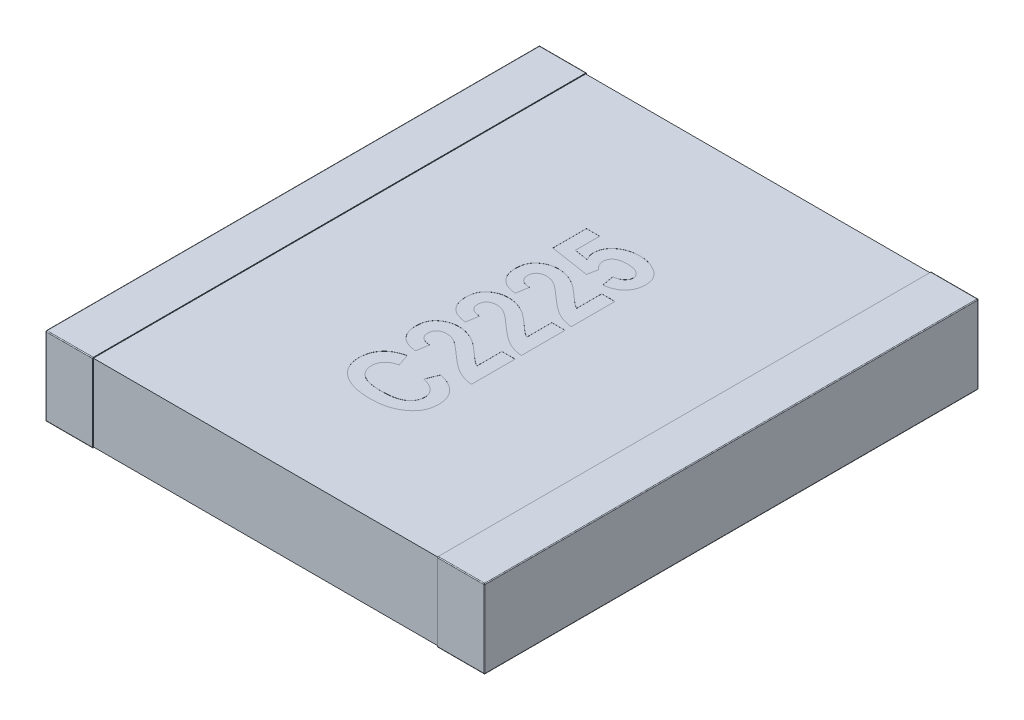
from build123d import *

# Parameters (mm, degrees)
SKETCH1_W            = 0.6
SKETCH1_H            = 6.3
THICKNESS_DEPTH      = 1
FILLET1_R            = 0.01
SKETCH2_W            = 6.28
SKETCH2_H            = 0.98
BOSS_EXTRUDE2_DEPTH  = 2.2
FILLET1_OF_MIRROR3_R = 0.01
CUT_EXTRUDE1_DEPTH   = 0.001


with BuildPart() as part:
    # Sketch1 → THICKNESS (new body)
    with BuildSketch(Plane(origin=(0, 0, 0), x_dir=(1, 0, 0), z_dir=(0, 1, 0))):
        with Locations((-2.5, 0)):
            Rectangle(SKETCH1_W, SKETCH1_H)
    thickness = extrude(amount=THICKNESS_DEPTH)

    # Fillet1
    fillet1_edges = [part.edges().sort_by_distance(p)[0] for p in [
        (-2.5, 1, -3.15),
        (-2.8, 1, 0),
        (-2.5, 0, -3.15),
        (-2.5, 0, 3.15),
        (-2.8, 0, 0),
        (-2.5, 1, 3.15),
        (-2.8, 0.5, -3.15),
        (-2.8, 0.5, 3.15),
    ]]
    fillet(fillet1_edges, radius=FILLET1_R)

    # Sketch2 → Boss-Extrude2 (add)
    with BuildSketch(Plane(origin=(0, 0, 0), x_dir=(0, 0, -1), z_dir=(1, 0, 0))):
        with Locations((0, 0.5)):
            Rectangle(SKETCH2_W, SKETCH2_H)
    boss_extrude2 = extrude(amount=-BOSS_EXTRUDE2_DEPTH)

    # Mirror3: THICKNESS, Boss-Extrude2 across plane
    add(thickness.mirror(Plane(origin=(0, 0, 0), x_dir=(0, 0, 1), z_dir=(1, 0, 0))))
    add(boss_extrude2.mirror(Plane(origin=(0, 0, 0), x_dir=(0, 0, 1), z_dir=(1, 0, 0))))

    # Fillet1 of Mirror3
    fillet1_of_mirror3_edges = [part.edges().sort_by_distance(p)[0] for p in [
        (2.5, 1, -3.15),
        (2.8, 1, 0),
        (2.5, 0, -3.15),
        (2.5, 0, 3.15),
        (2.8, 0, 0),
        (2.5, 1, 3.15),
        (2.8, 0.5, -3.15),
        (2.8, 0.5, 3.15),
    ]]
    fillet(fillet1_of_mirror3_edges, radius=FILLET1_OF_MIRROR3_R)

    # Sketch3 → Cut-Extrude1 (cut)
    with BuildSketch(Plane(origin=(0, 0.99, 0), x_dir=(1, 0, 0), z_dir=(0, 1, 0))):
        with BuildLine():
            Line((0.136363636, -1.26461039), (0.201298701, -1.108766234))
            add(Edge.make_bspline(
                [(0.201298701, -1.108766234), (0.214398679, -1.111985135), (0.239924634, -1.118257322), (0.276411029, -1.130118641), (0.310255179, -1.143188018), (0.341258619, -1.158054192), (0.369599325, -1.174483479), (0.395222463, -1.192525745), (0.418170449, -1.212112299), (0.438365598, -1.233268297), (0.455765912, -1.255956545), (0.471194946, -1.279625275), (0.484182898, -1.304628847), (0.4948407, -1.330978242), (0.502829618, -1.358620135), (0.508820757, -1.387435299), (0.512253899, -1.417530362), (0.512739893, -1.438032668), (0.512987013, -1.448457792)],
                knots=[0, 0, 0, 0, 4.0457e-05, 7.8832e-05, 0.000115008, 0.000149225, 0.00018187, 0.000213174, 0.000243107, 0.000272244, 0.000300738, 0.000328768, 0.000356904, 0.000385128, 0.000413894, 0.000443105, 0.000473335, 0.000504609, 0.000504609, 0.000504609, 0.000504609], degree=3))
            add(Edge.make_bspline(
                [(0.512987013, -1.448457792), (0.512692936, -1.461538079), (0.512116846, -1.487162052), (0.505918262, -1.524552352), (0.496500592, -1.560132443), (0.48297676, -1.593838191), (0.465690424, -1.625709563), (0.444278756, -1.655409865), (0.419538879, -1.683632129), (0.400249065, -1.700041432), (0.390422078, -1.708400974)],
                knots=[0, 0, 0, 0, 3.9207e-05, 7.6805e-05, 0.000113379, 0.00014944, 0.00018549, 0.000221864, 0.00025909, 0.000297748, 0.000297748, 0.000297748, 0.000297748], degree=3))
            add(Edge.make_bspline(
                [(0.390422078, -1.708400974), (0.378289428, -1.717589791), (0.353847085, -1.736101511), (0.313541703, -1.759341949), (0.270240344, -1.779108387), (0.223903762, -1.795286241), (0.17448062, -1.807896026), (0.121947356, -1.816711903), (0.066329381, -1.822006106), (0.028218004, -1.822698049), (0.008725649, -1.823051948)],
                knots=[0, 0, 0, 0, 4.5623e-05, 9.1911e-05, 0.00013922, 0.000188252, 0.000238945, 0.000292054, 0.000347905, 0.000406375, 0.000406375, 0.000406375, 0.000406375], degree=3))
            add(Edge.make_bspline(
                [(0.008725649, -1.823051948), (-0.011851286, -1.822728635), (-0.051931704, -1.822098877), (-0.110284982, -1.816428854), (-0.165298235, -1.807785146), (-0.216766987, -1.794897738), (-0.264986777, -1.77875342), (-0.309656912, -1.758807161), (-0.351244574, -1.735647553), (-0.376082128, -1.71675196), (-0.388392857, -1.707386364)],
                knots=[0, 0, 0, 0, 6.1715e-05, 0.000120211, 0.000175723, 0.00022863, 0.000279196, 0.000328068, 0.000375235, 0.000421589, 0.000421589, 0.000421589, 0.000421589], degree=3))
            add(Edge.make_bspline(
                [(-0.388392857, -1.707386364), (-0.398345965, -1.698883783), (-0.417961407, -1.68212702), (-0.443331204, -1.653469471), (-0.46499687, -1.622771098), (-0.482313096, -1.589708631), (-0.496435559, -1.554719195), (-0.506038208, -1.517403394), (-0.511790154, -1.477925698), (-0.512581962, -1.450912702), (-0.512987013, -1.437094156)],
                knots=[0, 0, 0, 0, 3.9231e-05, 7.7316e-05, 0.000114471, 0.000151689, 0.000189032, 0.000227423, 0.000266997, 0.000308443, 0.000308443, 0.000308443, 0.000308443], degree=3))
            add(Edge.make_bspline(
                [(-0.512987013, -1.437094156), (-0.512716343, -1.425786249), (-0.512184355, -1.40356109), (-0.507931398, -1.370971923), (-0.500453169, -1.339922729), (-0.490644065, -1.310110424), (-0.477519585, -1.281796563), (-0.461593795, -1.254899278), (-0.442919053, -1.229312793), (-0.428401184, -1.213804419), (-0.421063312, -1.205965909)],
                knots=[0, 0, 0, 0, 3.3918e-05, 6.6664e-05, 9.8361e-05, 0.000129612, 0.000160664, 0.000191777, 0.000223272, 0.000255459, 0.000255459, 0.000255459, 0.000255459], degree=3))
            add(Edge.make_bspline(
                [(-0.421063312, -1.205965909), (-0.415407881, -1.200515869), (-0.403883704, -1.18941022), (-0.384471947, -1.174456438), (-0.363093659, -1.160611831), (-0.339657607, -1.148124617), (-0.314392853, -1.136515651), (-0.28716989, -1.12595942), (-0.257926787, -1.116672878), (-0.237648602, -1.111442498), (-0.227272727, -1.108766234)],
                knots=[0, 0, 0, 0, 2.3548e-05, 4.7984e-05, 7.3368e-05, 9.988e-05, 0.000127573, 0.00015674, 0.000187416, 0.000219558, 0.000219558, 0.000219558, 0.000219558], degree=3))
            Line((-0.227272727, -1.108766234), (-0.175324675, -1.26461039))
            add(Edge.make_bspline(
                [(-0.175324675, -1.26461039), (-0.181975902, -1.266074849), (-0.194918084, -1.268924443), (-0.213595413, -1.274645704), (-0.230942941, -1.28161111), (-0.247377118, -1.289189563), (-0.262329513, -1.298315282), (-0.276514559, -1.307861071), (-0.28908196, -1.319054403), (-0.300692084, -1.330879848), (-0.310725155, -1.343754524), (-0.319798502, -1.356932912), (-0.327342325, -1.37080791), (-0.333409456, -1.385321642), (-0.338319598, -1.400302206), (-0.341772531, -1.415861229), (-0.34386351, -1.431963105), (-0.34405743, -1.442904873), (-0.344155844, -1.448457792)],
                knots=[0, 0, 0, 0, 2.0427e-05, 3.9747e-05, 5.8513e-05, 7.6485e-05, 9.3955e-05, 0.000111011, 0.000127695, 0.000144342, 0.000160663, 0.000176591, 0.0001923, 0.000207941, 0.000223727, 0.00023953, 0.000255689, 0.00027234, 0.00027234, 0.00027234, 0.00027234], degree=3))
            add(Edge.make_bspline(
                [(-0.344155844, -1.448457792), (-0.343922857, -1.456316567), (-0.343464314, -1.47178344), (-0.339815571, -1.494443473), (-0.333363218, -1.515883972), (-0.324888303, -1.536422831), (-0.313613243, -1.555733213), (-0.299927204, -1.573922482), (-0.283681663, -1.590818388), (-0.265141061, -1.606782958), (-0.243666159, -1.621411475), (-0.218738348, -1.633644713), (-0.190654932, -1.643900096), (-0.159545627, -1.652662188), (-0.125189618, -1.659232534), (-0.087627914, -1.663787955), (-0.046918653, -1.666632217), (-0.018673729, -1.667011522), (-0.004058442, -1.667207792)],
                knots=[0, 0, 0, 0, 2.357e-05, 4.6389e-05, 6.8605e-05, 9.0614e-05, 0.00011289, 0.000135495, 0.000158747, 0.000183068, 0.000208789, 0.000236468, 0.000266132, 0.000298382, 0.000333323, 0.000370951, 0.000411838, 0.00045568, 0.00045568, 0.00045568, 0.00045568], degree=3))
            add(Edge.make_bspline(
                [(-0.004058442, -1.667207792), (0.011095871, -1.666985985), (0.040278488, -1.666558851), (0.08242797, -1.664069004), (0.121153689, -1.659336396), (0.156607918, -1.653278299), (0.188583424, -1.64498836), (0.217099791, -1.634860599), (0.242435415, -1.623195029), (0.264257887, -1.609279255), (0.283097178, -1.593860302), (0.299453787, -1.577467135), (0.313117458, -1.559783266), (0.32469734, -1.541281785), (0.333472268, -1.52145475), (0.339442532, -1.500536726), (0.343571874, -1.478651768), (0.343958581, -1.463629112), (0.344155844, -1.455965909)],
                knots=[0, 0, 0, 0, 4.5466e-05, 8.7553e-05, 0.000126592, 0.000162456, 0.000195383, 0.00022555, 0.000253145, 0.000278871, 0.000302958, 0.000326059, 0.000348182, 0.000369864, 0.000391395, 0.00041297, 0.000435022, 0.000457984, 0.000457984, 0.000457984, 0.000457984], degree=3))
            add(Edge.make_bspline(
                [(0.344155844, -1.455965909), (0.343974101, -1.450347695), (0.343613575, -1.439202733), (0.341524436, -1.422749638), (0.337179679, -1.407037059), (0.33212763, -1.391651473), (0.324835159, -1.377083413), (0.316327699, -1.362949716), (0.306090095, -1.349513466), (0.294241166, -1.336708849), (0.280890082, -1.324504127), (0.265656465, -1.313231761), (0.248554845, -1.302946712), (0.229614222, -1.293426308), (0.208948136, -1.284715932), (0.186414075, -1.277031267), (0.162119865, -1.270078743), (0.145114413, -1.266468283), (0.136363636, -1.26461039)],
                knots=[0, 0, 0, 0, 1.6862e-05, 3.345e-05, 4.9593e-05, 6.5701e-05, 8.1946e-05, 9.8338e-05, 0.00011514, 0.000132516, 0.000150616, 0.000169326, 0.000189267, 0.000210412, 0.000232874, 0.00025649, 0.000281799, 0.000308629, 0.000308629, 0.000308629, 0.000308629], degree=3))
        make_face()
        with BuildLine():
            Line((0.331168831, -0.459415584), (0.5, -0.459415584))
            Line((0.5, -0.459415584), (0.5, -1.017857143))
            add(Edge.make_bspline(
                [(0.5, -1.017857143), (0.483371878, -1.015892291), (0.450160812, -1.011967927), (0.401416985, -1.000084764), (0.353798597, -0.984066439), (0.315024186, -0.966526313), (0.283716795, -0.949119933), (0.258172511, -0.933548747), (0.230990775, -0.915005151), (0.202208417, -0.893511307), (0.171398924, -0.869678521), (0.138885435, -0.842979694), (0.104639318, -0.813553873), (0.081403726, -0.792789394), (0.069399351, -0.782061688)],
                knots=[0, 0, 0, 0, 5.0192e-05, 0.000100248, 0.000150173, 0.000200756, 0.00022764, 0.000257605, 0.000290474, 0.000326311, 0.000365358, 0.00040732, 0.000452506, 0.000500804, 0.000500804, 0.000500804, 0.000500804], degree=3))
            add(Edge.make_bspline(
                [(0.069399351, -0.782061688), (0.060018232, -0.773650469), (0.042071313, -0.757559057), (0.016082491, -0.734925087), (-0.00728779, -0.714565899), (-0.028521986, -0.697130314), (-0.047176105, -0.682003958), (-0.06353451, -0.669467923), (-0.077455394, -0.659371865), (-0.086213896, -0.653975522), (-0.090097403, -0.651582792)],
                knots=[0, 0, 0, 0, 3.7799e-05, 7.2312e-05, 0.00010339, 0.000130775, 0.000154734, 0.000175433, 0.000192606, 0.000206286, 0.000206286, 0.000206286, 0.000206286], degree=3))
            add(Edge.make_bspline(
                [(-0.090097403, -0.651582792), (-0.100045175, -0.646029626), (-0.119463446, -0.635189724), (-0.150235139, -0.623901678), (-0.181062308, -0.61652335), (-0.201799466, -0.615677832), (-0.212053571, -0.61525974)],
                knots=[0, 0, 0, 0, 3.4128e-05, 6.6618e-05, 9.8026e-05, 0.000128749, 0.000128749, 0.000128749, 0.000128749], degree=3))
            add(Edge.make_bspline(
                [(-0.212053571, -0.61525974), (-0.22230063, -0.615615259), (-0.241698968, -0.616288277), (-0.268837794, -0.622164857), (-0.292263142, -0.631782125), (-0.311201971, -0.645916208), (-0.326112443, -0.662958398), (-0.336660208, -0.682820666), (-0.343144596, -0.70509122), (-0.343811987, -0.720801666), (-0.344155844, -0.728896104)],
                knots=[0, 0, 0, 0, 3.0708e-05, 5.8133e-05, 8.2859e-05, 0.000106074, 0.000128371, 0.000150251, 0.000173051, 0.000197284, 0.000197284, 0.000197284, 0.000197284], degree=3))
            add(Edge.make_bspline(
                [(-0.344155844, -0.728896104), (-0.343772419, -0.737670497), (-0.343037518, -0.754488158), (-0.336195521, -0.778141548), (-0.324916913, -0.798671474), (-0.308547663, -0.815495127), (-0.288097037, -0.829302728), (-0.262958615, -0.839271534), (-0.233609955, -0.84610636), (-0.212498526, -0.848013969), (-0.201298701, -0.849025974)],
                knots=[0, 0, 0, 0, 2.6272e-05, 5.0355e-05, 7.3159e-05, 9.5837e-05, 0.000120095, 0.000146662, 0.000176489, 0.000210192, 0.000210192, 0.000210192, 0.000210192], degree=3))
            Line((-0.201298701, -0.849025974), (-0.227272727, -1.00487013))
            add(Edge.make_bspline(
                [(-0.227272727, -1.00487013), (-0.238664931, -1.003565149), (-0.260764459, -1.00103364), (-0.292507359, -0.994330333), (-0.322012621, -0.986391685), (-0.349127549, -0.976451527), (-0.37388751, -0.964663722), (-0.396265212, -0.950988332), (-0.416637199, -0.935819653), (-0.43431516, -0.91839216), (-0.449781056, -0.899401271), (-0.463317835, -0.878975162), (-0.474637136, -0.856963449), (-0.484076171, -0.833558125), (-0.491064393, -0.808547357), (-0.496414197, -0.782185581), (-0.499431636, -0.754264017), (-0.499807758, -0.735193632), (-0.5, -0.725446429)],
                knots=[0, 0, 0, 0, 3.4382e-05, 6.6697e-05, 9.722e-05, 0.000125982, 0.00015321, 0.000179346, 0.00020455, 0.000229231, 0.000253603, 0.000277916, 0.000302603, 0.000327737, 0.000353492, 0.000380394, 0.00040836, 0.000437599, 0.000437599, 0.000437599, 0.000437599], degree=3))
            add(Edge.make_bspline(
                [(-0.5, -0.725446429), (-0.499707252, -0.714748711), (-0.49914014, -0.694025097), (-0.495333259, -0.663876643), (-0.488609048, -0.635888959), (-0.479514345, -0.609728461), (-0.467494659, -0.585778667), (-0.452919977, -0.56371043), (-0.435652695, -0.543793565), (-0.415760674, -0.526218603), (-0.39445374, -0.510527101), (-0.372035902, -0.496966792), (-0.349004815, -0.485171736), (-0.325006155, -0.475963616), (-0.30032419, -0.468554826), (-0.274925758, -0.463358785), (-0.248741747, -0.459912386), (-0.231004194, -0.459582902), (-0.221996753, -0.459415584)],
                knots=[0, 0, 0, 0, 3.2093e-05, 6.2171e-05, 9.0964e-05, 0.000118305, 0.000145076, 0.000171134, 0.000197458, 0.000223899, 0.000250604, 0.00027674, 0.000302423, 0.000328123, 0.00035374, 0.000379648, 0.000405824, 0.000432832, 0.000432832, 0.000432832, 0.000432832], degree=3))
            add(Edge.make_bspline(
                [(-0.221996753, -0.459415584), (-0.211773706, -0.459590374), (-0.191410581, -0.459938534), (-0.161178194, -0.463361848), (-0.131385861, -0.468565635), (-0.10202543, -0.476149683), (-0.072835323, -0.486003816), (-0.043622997, -0.497996531), (-0.014293782, -0.51220863), (0.010007277, -0.526203142), (0.030196203, -0.538742578), (0.04633337, -0.549908545), (0.063414235, -0.562633839), (0.081726202, -0.576561682), (0.100916784, -0.59223819), (0.121214355, -0.609281076), (0.142523538, -0.627749929), (0.156945101, -0.640671559), (0.164366883, -0.647321429)],
                knots=[0, 0, 0, 0, 3.0658e-05, 6.1067e-05, 9.116e-05, 0.00012133, 0.000151939, 0.000183517, 0.000216008, 0.000249634, 0.000267595, 0.000287295, 0.00030848, 0.000331493, 0.000356308, 0.000382809, 0.000411004, 0.000440899, 0.000440899, 0.000440899, 0.000440899], degree=3))
            add(Edge.make_bspline(
                [(0.164366883, -0.647321429), (0.171180839, -0.653496647), (0.184209265, -0.665303794), (0.203055408, -0.681820497), (0.219965729, -0.696701309), (0.234932252, -0.709879979), (0.248114972, -0.721334967), (0.259635965, -0.730767563), (0.269243968, -0.738543099), (0.283565888, -0.749965898), (0.30373791, -0.763614786), (0.322291451, -0.773484007), (0.331168831, -0.778206169)],
                knots=[0, 0, 0, 0, 2.7587e-05, 5.2747e-05, 7.5177e-05, 9.5163e-05, 0.000112573, 0.000127565, 0.000139829, 0.000149654, 0.000182523, 0.000212679, 0.000212679, 0.000212679, 0.000212679], degree=3))
            Line((0.331168831, -0.778206169), (0.331168831, -0.459415584))
        make_face()
        with BuildLine():
            Line((0.331168831, 0.176948052), (0.5, 0.176948052))
            Line((0.5, 0.176948052), (0.5, -0.381493506))
            add(Edge.make_bspline(
                [(0.5, -0.381493506), (0.483371878, -0.379528655), (0.450160812, -0.37560429), (0.401416985, -0.363721127), (0.353798597, -0.347702803), (0.315024186, -0.330162677), (0.283716795, -0.312756297), (0.258172511, -0.29718511), (0.230990775, -0.278641515), (0.202208417, -0.25714767), (0.171398924, -0.233314885), (0.138885435, -0.206616058), (0.104639318, -0.177190236), (0.081403726, -0.156425758), (0.069399351, -0.145698052)],
                knots=[0, 0, 0, 0, 5.0192e-05, 0.000100248, 0.000150173, 0.000200756, 0.00022764, 0.000257605, 0.000290474, 0.000326311, 0.000365358, 0.00040732, 0.000452506, 0.000500804, 0.000500804, 0.000500804, 0.000500804], degree=3))
            add(Edge.make_bspline(
                [(0.069399351, -0.145698052), (0.060018232, -0.137286833), (0.042071313, -0.12119542), (0.016082491, -0.098561451), (-0.00728779, -0.078202263), (-0.028521986, -0.060766677), (-0.047176105, -0.045640321), (-0.06353451, -0.033104287), (-0.077455394, -0.023008229), (-0.086213896, -0.017611886), (-0.090097403, -0.015219156)],
                knots=[0, 0, 0, 0, 3.7799e-05, 7.2312e-05, 0.00010339, 0.000130775, 0.000154734, 0.000175433, 0.000192606, 0.000206286, 0.000206286, 0.000206286, 0.000206286], degree=3))
            add(Edge.make_bspline(
                [(-0.090097403, -0.015219156), (-0.100045175, -0.00966599), (-0.119463446, 0.001173913), (-0.150235139, 0.012461958), (-0.181062308, 0.019840286), (-0.201799466, 0.020685804), (-0.212053571, 0.021103896)],
                knots=[0, 0, 0, 0, 3.4128e-05, 6.6618e-05, 9.8026e-05, 0.000128749, 0.000128749, 0.000128749, 0.000128749], degree=3))
            add(Edge.make_bspline(
                [(-0.212053571, 0.021103896), (-0.22230063, 0.020748378), (-0.241698968, 0.020075359), (-0.268837794, 0.01419878), (-0.292263142, 0.004581511), (-0.311201971, -0.009552572), (-0.326112443, -0.026594762), (-0.336660208, -0.04645703), (-0.343144596, -0.068727584), (-0.343811987, -0.08443803), (-0.344155844, -0.092532468)],
                knots=[0, 0, 0, 0, 3.0708e-05, 5.8133e-05, 8.2859e-05, 0.000106074, 0.000128371, 0.000150251, 0.000173051, 0.000197284, 0.000197284, 0.000197284, 0.000197284], degree=3))
            add(Edge.make_bspline(
                [(-0.344155844, -0.092532468), (-0.343772419, -0.10130686), (-0.343037518, -0.118124521), (-0.336195521, -0.141777911), (-0.324916913, -0.162307837), (-0.308547663, -0.179131491), (-0.288097037, -0.192939091), (-0.262958615, -0.202907897), (-0.233609955, -0.209742724), (-0.212498526, -0.211650332), (-0.201298701, -0.212662338)],
                knots=[0, 0, 0, 0, 2.6272e-05, 5.0355e-05, 7.3159e-05, 9.5837e-05, 0.000120095, 0.000146662, 0.000176489, 0.000210192, 0.000210192, 0.000210192, 0.000210192], degree=3))
            Line((-0.201298701, -0.212662338), (-0.227272727, -0.368506494))
            add(Edge.make_bspline(
                [(-0.227272727, -0.368506494), (-0.238664931, -0.367201512), (-0.260764459, -0.364670003), (-0.292507359, -0.357966697), (-0.322012621, -0.350028049), (-0.349127549, -0.34008789), (-0.37388751, -0.328300085), (-0.396265212, -0.314624695), (-0.416637199, -0.299456017), (-0.43431516, -0.282028523), (-0.449781056, -0.263037635), (-0.463317835, -0.242611526), (-0.474637136, -0.220599813), (-0.484076171, -0.197194489), (-0.491064393, -0.17218372), (-0.496414197, -0.145821945), (-0.499431636, -0.11790038), (-0.499807758, -0.098829996), (-0.5, -0.089082792)],
                knots=[0, 0, 0, 0, 3.4382e-05, 6.6697e-05, 9.722e-05, 0.000125982, 0.00015321, 0.000179346, 0.00020455, 0.000229231, 0.000253603, 0.000277916, 0.000302603, 0.000327737, 0.000353492, 0.000380394, 0.00040836, 0.000437599, 0.000437599, 0.000437599, 0.000437599], degree=3))
            add(Edge.make_bspline(
                [(-0.5, -0.089082792), (-0.499707252, -0.078385075), (-0.49914014, -0.05766146), (-0.495333259, -0.027513007), (-0.488609048, 0.000474678), (-0.479514345, 0.026635175), (-0.467494659, 0.050584969), (-0.452919977, 0.072653206), (-0.435652695, 0.092570071), (-0.415760674, 0.110145033), (-0.39445374, 0.125836536), (-0.372035902, 0.139396844), (-0.349004815, 0.151191901), (-0.325006155, 0.160400021), (-0.30032419, 0.16780881), (-0.274925758, 0.173004852), (-0.248741747, 0.176451251), (-0.231004194, 0.176780734), (-0.221996753, 0.176948052)],
                knots=[0, 0, 0, 0, 3.2093e-05, 6.2171e-05, 9.0964e-05, 0.000118305, 0.000145076, 0.000171134, 0.000197458, 0.000223899, 0.000250604, 0.00027674, 0.000302423, 0.000328123, 0.00035374, 0.000379648, 0.000405824, 0.000432832, 0.000432832, 0.000432832, 0.000432832], degree=3))
            add(Edge.make_bspline(
                [(-0.221996753, 0.176948052), (-0.211773706, 0.176773263), (-0.191410581, 0.176425102), (-0.161178194, 0.173001789), (-0.131385861, 0.167798002), (-0.10202543, 0.160213954), (-0.072835323, 0.150359821), (-0.043622997, 0.138367105), (-0.014293782, 0.124155006), (0.010007277, 0.110160495), (0.030196203, 0.097621059), (0.04633337, 0.086455091), (0.063414235, 0.073729797), (0.081726202, 0.059801955), (0.100916784, 0.044125446), (0.121214355, 0.027082561), (0.142523538, 0.008613708), (0.156945101, -0.004307922), (0.164366883, -0.010957792)],
                knots=[0, 0, 0, 0, 3.0658e-05, 6.1067e-05, 9.116e-05, 0.00012133, 0.000151939, 0.000183517, 0.000216008, 0.000249634, 0.000267595, 0.000287295, 0.00030848, 0.000331493, 0.000356308, 0.000382809, 0.000411004, 0.000440899, 0.000440899, 0.000440899, 0.000440899], degree=3))
            add(Edge.make_bspline(
                [(0.164366883, -0.010957792), (0.171180839, -0.017133011), (0.184209265, -0.028940158), (0.203055408, -0.045456861), (0.219965729, -0.060337673), (0.234932252, -0.073516342), (0.248114972, -0.084971331), (0.259635965, -0.094403927), (0.269243968, -0.102179463), (0.283565888, -0.113602261), (0.30373791, -0.127251149), (0.322291451, -0.13712037), (0.331168831, -0.141842532)],
                knots=[0, 0, 0, 0, 2.7587e-05, 5.2747e-05, 7.5177e-05, 9.5163e-05, 0.000112573, 0.000127565, 0.000139829, 0.000149654, 0.000182523, 0.000212679, 0.000212679, 0.000212679, 0.000212679], degree=3))
            Line((0.331168831, -0.141842532), (0.331168831, 0.176948052))
        make_face()
        with BuildLine():
            Line((0.331168831, 0.813311688), (0.5, 0.813311688))
            Line((0.5, 0.813311688), (0.5, 0.25487013))
            add(Edge.make_bspline(
                [(0.5, 0.25487013), (0.483371878, 0.256834981), (0.450160812, 0.260759346), (0.401416985, 0.272642509), (0.353798597, 0.288660833), (0.315024186, 0.306200959), (0.283716795, 0.323607339), (0.258172511, 0.339178526), (0.230990775, 0.357722121), (0.202208417, 0.379215966), (0.171398924, 0.403048752), (0.138885435, 0.429747579), (0.104639318, 0.4591734), (0.081403726, 0.479937879), (0.069399351, 0.490665584)],
                knots=[0, 0, 0, 0, 5.0192e-05, 0.000100248, 0.000150173, 0.000200756, 0.00022764, 0.000257605, 0.000290474, 0.000326311, 0.000365358, 0.00040732, 0.000452506, 0.000500804, 0.000500804, 0.000500804, 0.000500804], degree=3))
            add(Edge.make_bspline(
                [(0.069399351, 0.490665584), (0.060018232, 0.499076803), (0.042071313, 0.515168216), (0.016082491, 0.537802186), (-0.00728779, 0.558161374), (-0.028521986, 0.575596959), (-0.047176105, 0.590723315), (-0.06353451, 0.603259349), (-0.077455394, 0.613355408), (-0.086213896, 0.61875175), (-0.090097403, 0.621144481)],
                knots=[0, 0, 0, 0, 3.7799e-05, 7.2312e-05, 0.00010339, 0.000130775, 0.000154734, 0.000175433, 0.000192606, 0.000206286, 0.000206286, 0.000206286, 0.000206286], degree=3))
            add(Edge.make_bspline(
                [(-0.090097403, 0.621144481), (-0.100045175, 0.626697646), (-0.119463446, 0.637537549), (-0.150235139, 0.648825594), (-0.181062308, 0.656203922), (-0.201799466, 0.657049441), (-0.212053571, 0.657467532)],
                knots=[0, 0, 0, 0, 3.4128e-05, 6.6618e-05, 9.8026e-05, 0.000128749, 0.000128749, 0.000128749, 0.000128749], degree=3))
            add(Edge.make_bspline(
                [(-0.212053571, 0.657467532), (-0.22230063, 0.657112014), (-0.241698968, 0.656438995), (-0.268837794, 0.650562416), (-0.292263142, 0.640945147), (-0.311201971, 0.626811065), (-0.326112443, 0.609768875), (-0.336660208, 0.589906606), (-0.343144596, 0.567636053), (-0.343811987, 0.551925607), (-0.344155844, 0.543831169)],
                knots=[0, 0, 0, 0, 3.0708e-05, 5.8133e-05, 8.2859e-05, 0.000106074, 0.000128371, 0.000150251, 0.000173051, 0.000197284, 0.000197284, 0.000197284, 0.000197284], degree=3))
            add(Edge.make_bspline(
                [(-0.344155844, 0.543831169), (-0.343772419, 0.535056776), (-0.343037518, 0.518239115), (-0.336195521, 0.494585725), (-0.324916913, 0.474055799), (-0.308547663, 0.457232146), (-0.288097037, 0.443424545), (-0.262958615, 0.433455739), (-0.233609955, 0.426620913), (-0.212498526, 0.424713304), (-0.201298701, 0.423701299)],
                knots=[0, 0, 0, 0, 2.6272e-05, 5.0355e-05, 7.3159e-05, 9.5837e-05, 0.000120095, 0.000146662, 0.000176489, 0.000210192, 0.000210192, 0.000210192, 0.000210192], degree=3))
            Line((-0.201298701, 0.423701299), (-0.227272727, 0.267857143))
            add(Edge.make_bspline(
                [(-0.227272727, 0.267857143), (-0.238664931, 0.269162124), (-0.260764459, 0.271693633), (-0.292507359, 0.278396939), (-0.322012621, 0.286335587), (-0.349127549, 0.296275746), (-0.37388751, 0.308063551), (-0.396265212, 0.321738941), (-0.416637199, 0.336907619), (-0.43431516, 0.354335113), (-0.449781056, 0.373326001), (-0.463317835, 0.39375211), (-0.474637136, 0.415763823), (-0.484076171, 0.439169148), (-0.491064393, 0.464179916), (-0.496414197, 0.490541692), (-0.499431636, 0.518463256), (-0.499807758, 0.537533641), (-0.5, 0.547280844)],
                knots=[0, 0, 0, 0, 3.4382e-05, 6.6697e-05, 9.722e-05, 0.000125982, 0.00015321, 0.000179346, 0.00020455, 0.000229231, 0.000253603, 0.000277916, 0.000302603, 0.000327737, 0.000353492, 0.000380394, 0.00040836, 0.000437599, 0.000437599, 0.000437599, 0.000437599], degree=3))
            add(Edge.make_bspline(
                [(-0.5, 0.547280844), (-0.499707252, 0.557978561), (-0.49914014, 0.578702176), (-0.495333259, 0.60885063), (-0.488609048, 0.636838314), (-0.479514345, 0.662998811), (-0.467494659, 0.686948605), (-0.452919977, 0.709016842), (-0.435652695, 0.728933707), (-0.415760674, 0.74650867), (-0.39445374, 0.762200172), (-0.372035902, 0.77576048), (-0.349004815, 0.787555537), (-0.325006155, 0.796763657), (-0.30032419, 0.804172446), (-0.274925758, 0.809368488), (-0.248741747, 0.812814887), (-0.231004194, 0.813144371), (-0.221996753, 0.813311688)],
                knots=[0, 0, 0, 0, 3.2093e-05, 6.2171e-05, 9.0964e-05, 0.000118305, 0.000145076, 0.000171134, 0.000197458, 0.000223899, 0.000250604, 0.00027674, 0.000302423, 0.000328123, 0.00035374, 0.000379648, 0.000405824, 0.000432832, 0.000432832, 0.000432832, 0.000432832], degree=3))
            add(Edge.make_bspline(
                [(-0.221996753, 0.813311688), (-0.211773706, 0.813136899), (-0.191410581, 0.812788739), (-0.161178194, 0.809365425), (-0.131385861, 0.804161638), (-0.10202543, 0.79657759), (-0.072835323, 0.786723457), (-0.043622997, 0.774730742), (-0.014293782, 0.760518643), (0.010007277, 0.746524131), (0.030196203, 0.733984695), (0.04633337, 0.722818727), (0.063414235, 0.710093434), (0.081726202, 0.696165591), (0.100916784, 0.680489082), (0.121214355, 0.663446197), (0.142523538, 0.644977344), (0.156945101, 0.632055714), (0.164366883, 0.625405844)],
                knots=[0, 0, 0, 0, 3.0658e-05, 6.1067e-05, 9.116e-05, 0.00012133, 0.000151939, 0.000183517, 0.000216008, 0.000249634, 0.000267595, 0.000287295, 0.00030848, 0.000331493, 0.000356308, 0.000382809, 0.000411004, 0.000440899, 0.000440899, 0.000440899, 0.000440899], degree=3))
            add(Edge.make_bspline(
                [(0.164366883, 0.625405844), (0.171180839, 0.619230626), (0.184209265, 0.607423479), (0.203055408, 0.590906776), (0.219965729, 0.576025964), (0.234932252, 0.562847294), (0.248114972, 0.551392306), (0.259635965, 0.54195971), (0.269243968, 0.534184174), (0.283565888, 0.522761375), (0.30373791, 0.509112487), (0.322291451, 0.499243266), (0.331168831, 0.494521104)],
                knots=[0, 0, 0, 0, 2.7587e-05, 5.2747e-05, 7.5177e-05, 9.5163e-05, 0.000112573, 0.000127565, 0.000139829, 0.000149654, 0.000182523, 0.000212679, 0.000212679, 0.000212679, 0.000212679], degree=3))
            Line((0.331168831, 0.494521104), (0.331168831, 0.813311688))
        make_face()
        with BuildLine():
            Line((0.24025974, 0.917207792), (0.214285714, 1.073051948))
            add(Edge.make_bspline(
                [(0.214285714, 1.073051948), (0.224824693, 1.074381248), (0.245036856, 1.076930645), (0.273334007, 1.085292355), (0.298151616, 1.097113416), (0.319133957, 1.112275533), (0.335602985, 1.129875128), (0.348119517, 1.14835265), (0.355668208, 1.168143842), (0.356653788, 1.181758626), (0.357142857, 1.18851461)],
                knots=[0, 0, 0, 0, 3.1828e-05, 6.1041e-05, 8.8087e-05, 0.000113941, 0.000138201, 0.000160039, 0.000180583, 0.00020082, 0.00020082, 0.00020082, 0.00020082], degree=3))
            add(Edge.make_bspline(
                [(0.357142857, 1.18851461), (0.35698325, 1.192517906), (0.356669609, 1.200384682), (0.354274292, 1.211952297), (0.350754906, 1.223157629), (0.345238805, 1.233811286), (0.338623665, 1.244163651), (0.330354823, 1.254028214), (0.320530221, 1.263292818), (0.309399428, 1.272320764), (0.296579254, 1.280373636), (0.282195736, 1.287565029), (0.266211228, 1.293584974), (0.248597638, 1.29839603), (0.229491334, 1.302292883), (0.208791867, 1.304788906), (0.186512857, 1.306467761), (0.171134378, 1.306698417), (0.163149351, 1.306818182)],
                knots=[0, 0, 0, 0, 1.2e-05, 2.3581e-05, 3.5324e-05, 4.7121e-05, 5.9448e-05, 7.2127e-05, 8.5618e-05, 9.991e-05, 0.000115054, 0.000130935, 0.000148083, 0.000166201, 0.000185661, 0.000206527, 0.000228705, 0.000252657, 0.000252657, 0.000252657, 0.000252657], degree=3))
            add(Edge.make_bspline(
                [(0.163149351, 1.306818182), (0.155638128, 1.306693912), (0.14107115, 1.306452908), (0.120001887, 1.304816789), (0.100396303, 1.302249327), (0.08231014, 1.298490654), (0.065832976, 1.29328065), (0.050694057, 1.287566689), (0.037123979, 1.280408415), (0.02526427, 1.272001113), (0.014513324, 1.263177652), (0.005668889, 1.253255151), (-0.002202355, 1.243134663), (-0.008582055, 1.232239514), (-0.013423044, 1.220685195), (-0.016836258, 1.208546925), (-0.019259219, 1.195915918), (-0.01940595, 1.187241281), (-0.019480519, 1.182832792)],
                knots=[0, 0, 0, 0, 2.2533e-05, 4.3699e-05, 6.3357e-05, 8.1824e-05, 9.9026e-05, 0.000115154, 0.000130314, 0.000144893, 0.000158716, 0.000171929, 0.000184673, 0.000197132, 0.000209682, 0.000222142, 0.000234919, 0.000248123, 0.000248123, 0.000248123, 0.000248123], degree=3))
            add(Edge.make_bspline(
                [(-0.019480519, 1.182832792), (-0.019288214, 1.177204678), (-0.018905391, 1.16600079), (-0.015728115, 1.149436991), (-0.010633212, 1.133290548), (-0.003449867, 1.11756758), (0.005775665, 1.102282976), (0.016968452, 1.087436376), (0.030335615, 1.073137524), (0.040307377, 1.06424776), (0.045454545, 1.059659091)],
                knots=[0, 0, 0, 0, 1.6873e-05, 3.3589e-05, 5.0404e-05, 6.7567e-05, 8.5315e-05, 0.000103863, 0.000123247, 0.000143927, 0.000143927, 0.000143927, 0.000143927], degree=3))
            Line((0.045454545, 1.059659091), (0.019480519, 0.930194805))
            Line((0.019480519, 0.930194805), (-0.487012987, 1.008116883))
            Line((-0.487012987, 1.008116883), (-0.487012987, 1.436688312))
            Line((-0.487012987, 1.436688312), (-0.318181818, 1.436688312))
            Line((-0.318181818, 1.436688312), (-0.318181818, 1.126420455))
            Line((-0.318181818, 1.126420455), (-0.137581169, 1.09862013))
            add(Edge.make_bspline(
                [(-0.137581169, 1.09862013), (-0.143340147, 1.107875081), (-0.154523758, 1.125847672), (-0.166240843, 1.154554987), (-0.173860629, 1.183318039), (-0.174839856, 1.202673524), (-0.175324675, 1.212256494)],
                knots=[0, 0, 0, 0, 3.2646e-05, 6.3396e-05, 9.268e-05, 0.000121395, 0.000121395, 0.000121395, 0.000121395], degree=3))
            add(Edge.make_bspline(
                [(-0.175324675, 1.212256494), (-0.175109296, 1.220659809), (-0.174686831, 1.237142879), (-0.170799885, 1.261316654), (-0.165054231, 1.28465432), (-0.156438725, 1.30691984), (-0.145589307, 1.328295137), (-0.132296312, 1.348547611), (-0.116876446, 1.368125639), (-0.104785365, 1.379801404), (-0.09862013, 1.38575487)],
                knots=[0, 0, 0, 0, 2.5192e-05, 4.9414e-05, 7.3283e-05, 9.7177e-05, 0.000120863, 0.000145065, 0.000169753, 0.000195437, 0.000195437, 0.000195437, 0.000195437], degree=3))
            add(Edge.make_bspline(
                [(-0.09862013, 1.38575487), (-0.090317008, 1.392984096), (-0.073728999, 1.407426673), (-0.046044988, 1.425643327), (-0.016539454, 1.441141376), (0.014924387, 1.453660902), (0.048200563, 1.463821257), (0.083600362, 1.470432643), (0.120827493, 1.474902327), (0.146292926, 1.475396871), (0.159293831, 1.475649351)],
                knots=[0, 0, 0, 0, 3.2997e-05, 6.5921e-05, 9.9141e-05, 0.000132829, 0.000167367, 0.000203343, 0.000240722, 0.000279709, 0.000279709, 0.000279709, 0.000279709], degree=3))
            add(Edge.make_bspline(
                [(0.159293831, 1.475649351), (0.170193215, 1.475404324), (0.191843162, 1.474917616), (0.223919445, 1.471358277), (0.255411081, 1.465713118), (0.286192139, 1.457564086), (0.31631158, 1.447202026), (0.345750226, 1.434517765), (0.374490293, 1.419498265), (0.402268995, 1.402444971), (0.428317599, 1.383524986), (0.450915015, 1.361859657), (0.47016828, 1.33838005), (0.486125577, 1.312980357), (0.497953639, 1.285305756), (0.506859871, 1.255874507), (0.511888629, 1.224332303), (0.512614665, 1.202668647), (0.512987013, 1.191558442)],
                knots=[0, 0, 0, 0, 3.2693e-05, 6.494e-05, 9.6702e-05, 0.000128596, 0.000160362, 0.000192176, 0.000224669, 0.000257558, 0.000289904, 0.000321049, 0.000351189, 0.000380808, 0.000410705, 0.0004412, 0.00047286, 0.000506189, 0.000506189, 0.000506189, 0.000506189], degree=3))
            add(Edge.make_bspline(
                [(0.512987013, 1.191558442), (0.512837699, 1.182549013), (0.512543524, 1.164798893), (0.508852182, 1.138752197), (0.503540441, 1.113780232), (0.495775851, 1.089944312), (0.485488033, 1.067415171), (0.473360284, 1.045777709), (0.458841853, 1.025398938), (0.44216269, 1.00633113), (0.423533437, 0.988658935), (0.402906821, 0.972801217), (0.380497324, 0.958633803), (0.355941769, 0.94682305), (0.329773287, 0.93631436), (0.301574638, 0.928207693), (0.271675222, 0.921264209), (0.250910954, 0.918583094), (0.24025974, 0.917207792)],
                knots=[0, 0, 0, 0, 2.7008e-05, 5.321e-05, 7.8763e-05, 0.000103533, 0.000128237, 0.000152954, 0.000177841, 0.000203153, 0.000228847, 0.000254743, 0.000281092, 0.000308227, 0.000336375, 0.000365588, 0.00039616, 0.000428359, 0.000428359, 0.000428359, 0.000428359], degree=3))
        make_face()
    extrude(amount=-CUT_EXTRUDE1_DEPTH, mode=Mode.SUBTRACT)


solid = part.part
